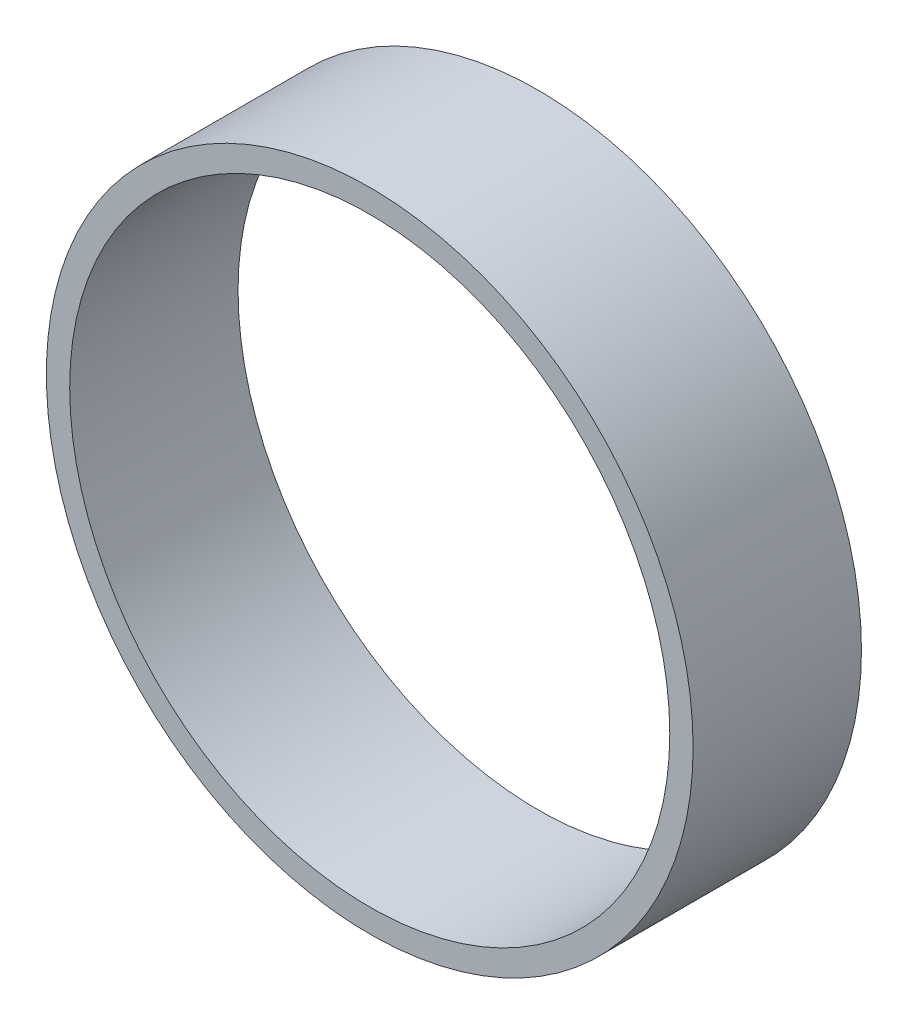
from build123d import *

# Parameters (mm, degrees)
SKETCH2_R           = 49.276
SKETCH2_R_2         = 45.72
BOSS_EXTRUDE1_DEPTH = 25.654


with BuildPart() as part:
    # Sketch2 → Boss-Extrude1 (new body)
    with BuildSketch(Plane.XY):
        Circle(SKETCH2_R)
        Circle(SKETCH2_R_2, mode=Mode.SUBTRACT)
    extrude(amount=BOSS_EXTRUDE1_DEPTH)


solid = part.part
